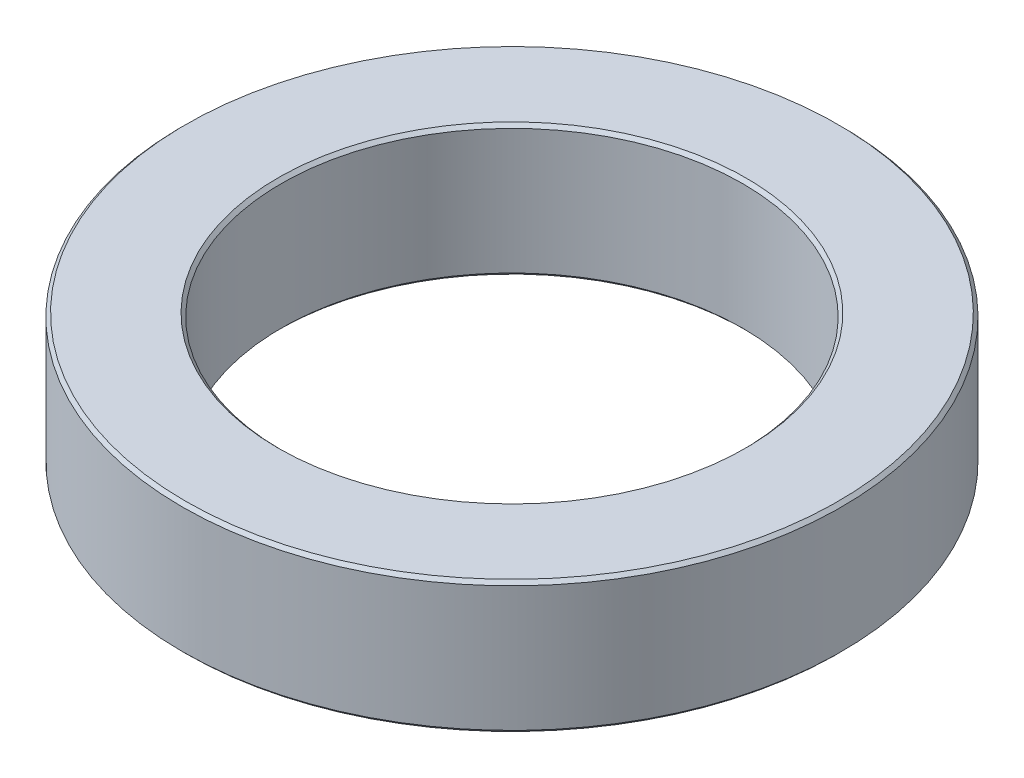
from build123d import *

# Parameters (mm, degrees)
SKETCH1_R           = 20
SKETCH1_R_2         = 14
BOSS_EXTRUDE1_DEPTH = 4
CHAMFER1_SIZE       = 0.2


with BuildPart() as part:
    # Sketch1 → Boss-Extrude1 (new body, symmetric)
    with BuildSketch(Plane(origin=(0, 0, 0), x_dir=(1, 0, 0), z_dir=(0, 1, 0))):
        Circle(SKETCH1_R)
        Circle(SKETCH1_R_2, mode=Mode.SUBTRACT)
    extrude(amount=BOSS_EXTRUDE1_DEPTH, both=True)

    # Chamfer1
    chamfer1_edges = [part.edges().sort_by_distance(p)[0] for p in [
        (-20, -4, 0),
        (-20, 4, 0),
        (-14, -4, 0),
        (-14, 4, 0),
    ]]
    chamfer(chamfer1_edges, length=CHAMFER1_SIZE)


solid = part.part
